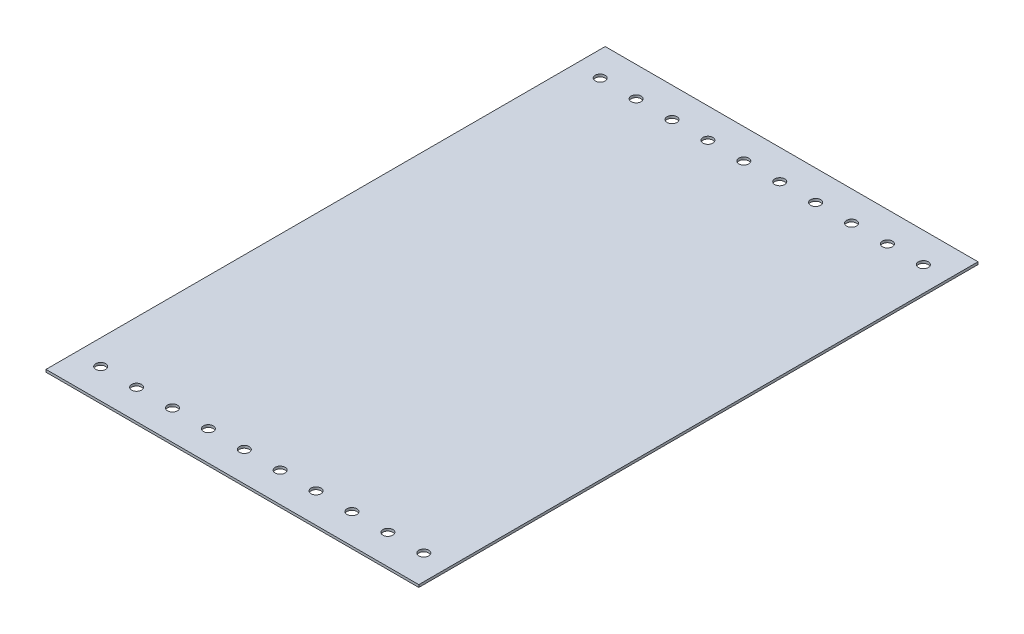
from build123d import *

# Parameters (mm, degrees)
SKETCH2_W           = 300
SKETCH2_H           = 450
BOSS_EXTRUDE1_DEPTH = 2
SKETCH3_R           = 4
CUT_EXTRUDE1_DEPTH  = 2


with BuildPart() as part:
    # Sketch2 → Boss-Extrude1 (new body)
    with BuildSketch(Plane(origin=(0, 0, 0), x_dir=(1, 0, 0), z_dir=(0, 1, 0))):
        Rectangle(SKETCH2_W, SKETCH2_H)
    extrude(amount=BOSS_EXTRUDE1_DEPTH)

    # Sketch3 → Cut-Extrude1 (cut)
    with BuildSketch(Plane(origin=(0, 2, 0), x_dir=(1, 0, 0), z_dir=(0, 1, 0))):
        with Locations((-130, 201)):
            Circle(SKETCH3_R)
        with Locations((-101.111111111, 201)):
            Circle(SKETCH3_R)
        with Locations((-72.222222222, 201)):
            Circle(SKETCH3_R)
        with Locations((-43.333333333, 201)):
            Circle(SKETCH3_R)
        with Locations((-14.444444444, 201)):
            Circle(SKETCH3_R)
        with Locations((14.444444444, 201)):
            Circle(SKETCH3_R)
        with Locations((43.333333333, 201)):
            Circle(SKETCH3_R)
        with Locations((72.222222222, 201)):
            Circle(SKETCH3_R)
        with Locations((101.111111111, 201)):
            Circle(SKETCH3_R)
        with Locations((130, 201)):
            Circle(SKETCH3_R)
        with Locations((130, -201)):
            Circle(SKETCH3_R)
        with Locations((101.111111111, -201)):
            Circle(SKETCH3_R)
        with Locations((72.222222222, -201)):
            Circle(SKETCH3_R)
        with Locations((43.333333333, -201)):
            Circle(SKETCH3_R)
        with Locations((14.444444444, -201)):
            Circle(SKETCH3_R)
        with Locations((-14.444444444, -201)):
            Circle(SKETCH3_R)
        with Locations((-43.333333333, -201)):
            Circle(SKETCH3_R)
        with Locations((-72.222222222, -201)):
            Circle(SKETCH3_R)
        with Locations((-101.111111111, -201)):
            Circle(SKETCH3_R)
        with Locations((-130, -201)):
            Circle(SKETCH3_R)
    extrude(amount=-CUT_EXTRUDE1_DEPTH, mode=Mode.SUBTRACT)


solid = part.part
